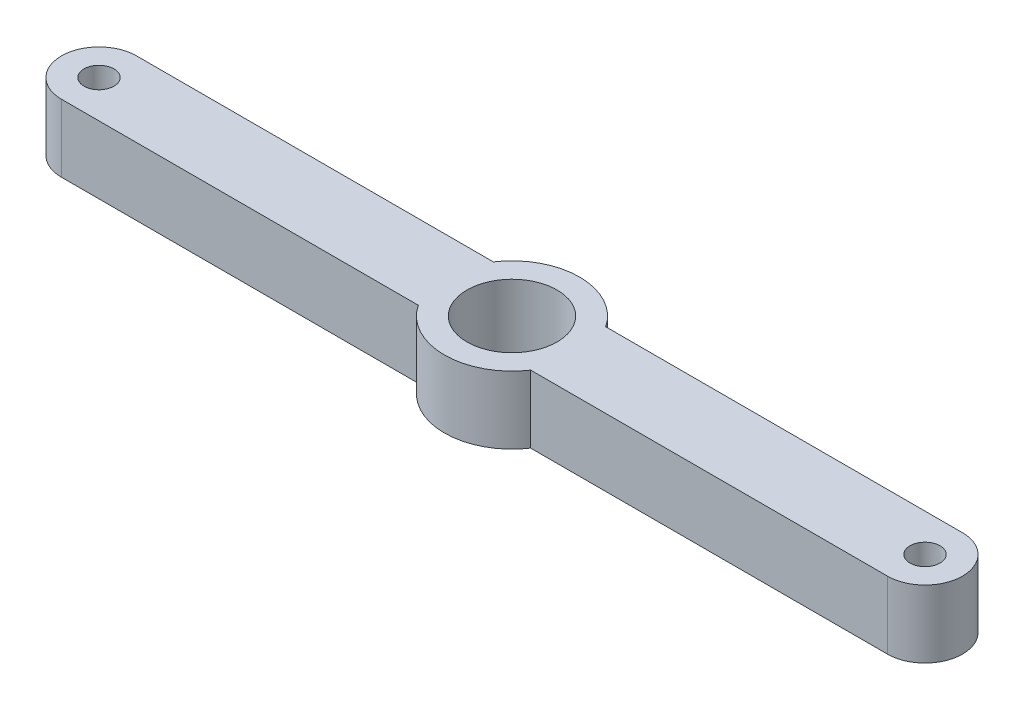
from build123d import *

# Parameters (mm, degrees)
BOSS_EXTRUDE2_DEPTH     = 4.5
SKETCH2_R               = 3
CUT_EXTRUDE1_DEPTH      = 5.5
CUT_EXTRUDE1_DEPTH_BACK = 1
SKETCH3_R               = 1
CUT_EXTRUDE2_DEPTH      = 5.5
CUT_EXTRUDE2_DEPTH_BACK = 1


with BuildPart() as part:
    # Sketch1 → Boss-Extrude2 (new body)
    with BuildSketch(Plane(origin=(0, 0, 0), x_dir=(1, 0, 0), z_dir=(0, 1, 0))):
        with BuildLine():
            Line((-3.741657387, 2.5), (-27.5, 2.5))
            ThreePointArc((-27.5, 2.5), (-30, 0), (-27.5, -2.5))
            Line((-27.5, -2.5), (-3.741657387, -2.5))
            ThreePointArc((-3.741657387, -2.5), (0, -4.5), (3.741657387, -2.5))
            Line((3.741657387, -2.5), (27.5, -2.5))
            ThreePointArc((27.5, -2.5), (30, 0), (27.5, 2.5))
            Line((27.5, 2.5), (3.741657387, 2.5))
            ThreePointArc((3.741657387, 2.5), (0, 4.5), (-3.741657387, 2.5))
        make_face()
    extrude(amount=BOSS_EXTRUDE2_DEPTH)

    # Sketch2 → Cut-Extrude1 (cut, two sides)
    with BuildSketch(Plane(origin=(0, 0, 0), x_dir=(1, 0, 0), z_dir=(0, 1, 0))) as cut_extrude1_sk:
        Circle(SKETCH2_R)
    extrude(amount=CUT_EXTRUDE1_DEPTH, mode=Mode.SUBTRACT)
    extrude(cut_extrude1_sk.sketch, amount=-CUT_EXTRUDE1_DEPTH_BACK, mode=Mode.SUBTRACT)

    # Sketch3 → Cut-Extrude2 (cut, two sides)
    with BuildSketch(Plane(origin=(0, 0, 0), x_dir=(1, 0, 0), z_dir=(0, 1, 0))) as cut_extrude2_sk:
        with Locations((-27.5, 0)):
            Circle(SKETCH3_R)
        with Locations((27.5, 0)):
            Circle(SKETCH3_R)
    extrude(amount=CUT_EXTRUDE2_DEPTH, mode=Mode.SUBTRACT)
    extrude(cut_extrude2_sk.sketch, amount=-CUT_EXTRUDE2_DEPTH_BACK, mode=Mode.SUBTRACT)


solid = part.part
